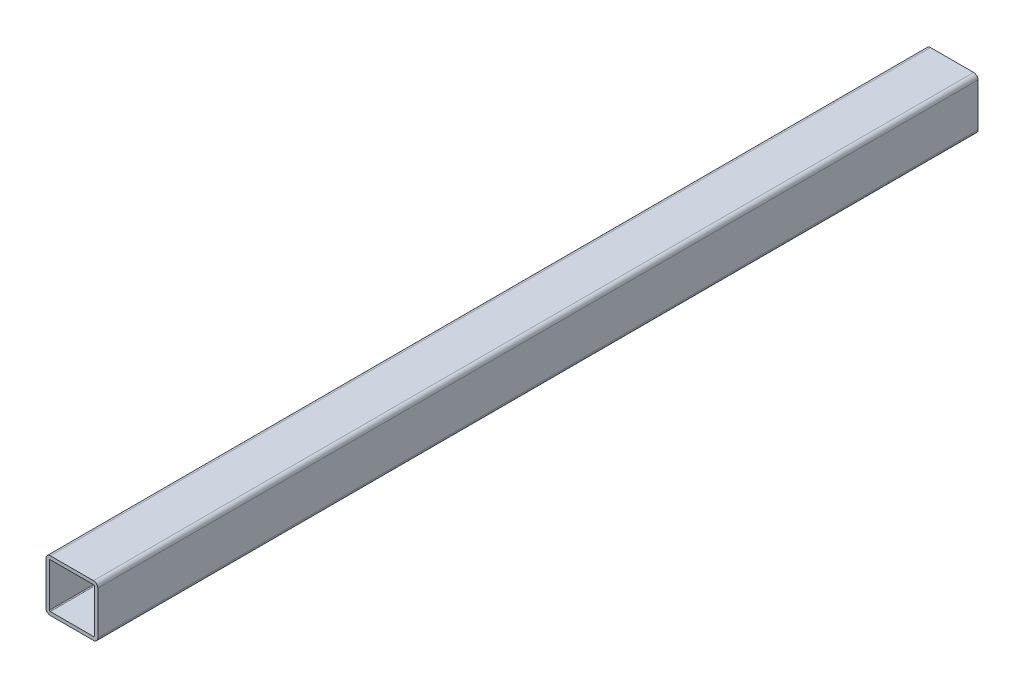
from build123d import *

# Parameters (mm, degrees)
EXTRUDE_THIN1_DEPTH = 323.85


with BuildPart() as part:
    # Sketch1 → Extrude-Thin1 (new body, symmetric)
    with BuildSketch(Plane.XY):
        with BuildLine():
            Line((-15.875, 19.05), (15.875, 19.05))
            ThreePointArc((15.875, 19.05), (18.12006403, 18.12006403), (19.05, 15.875))
            Line((19.05, 15.875), (19.05, -15.875))
            ThreePointArc((19.05, -15.875), (18.12006403, -18.12006403), (15.875, -19.05))
            Line((15.875, -19.05), (-15.875, -19.05))
            ThreePointArc((-15.875, -19.05), (-18.12006403, -18.12006403), (-19.05, -15.875))
            Line((-19.05, -15.875), (-19.05, 15.875))
            ThreePointArc((-19.05, 15.875), (-18.12006403, 18.12006403), (-15.875, 19.05))
        make_face()
        with BuildLine():
            Line((-15.875, 16.51), (15.875, 16.51))
            ThreePointArc((15.875, 16.51), (16.324012806, 16.324012806), (16.51, 15.875))
            Line((16.51, 15.875), (16.51, -15.875))
            ThreePointArc((16.51, -15.875), (16.324012806, -16.324012806), (15.875, -16.51))
            Line((15.875, -16.51), (-15.875, -16.51))
            ThreePointArc((-15.875, -16.51), (-16.324012806, -16.324012806), (-16.51, -15.875))
            Line((-16.51, -15.875), (-16.51, 15.875))
            ThreePointArc((-16.51, 15.875), (-16.324012806, 16.324012806), (-15.875, 16.51))
        make_face(mode=Mode.SUBTRACT)
    extrude(amount=EXTRUDE_THIN1_DEPTH, both=True)


solid = part.part
